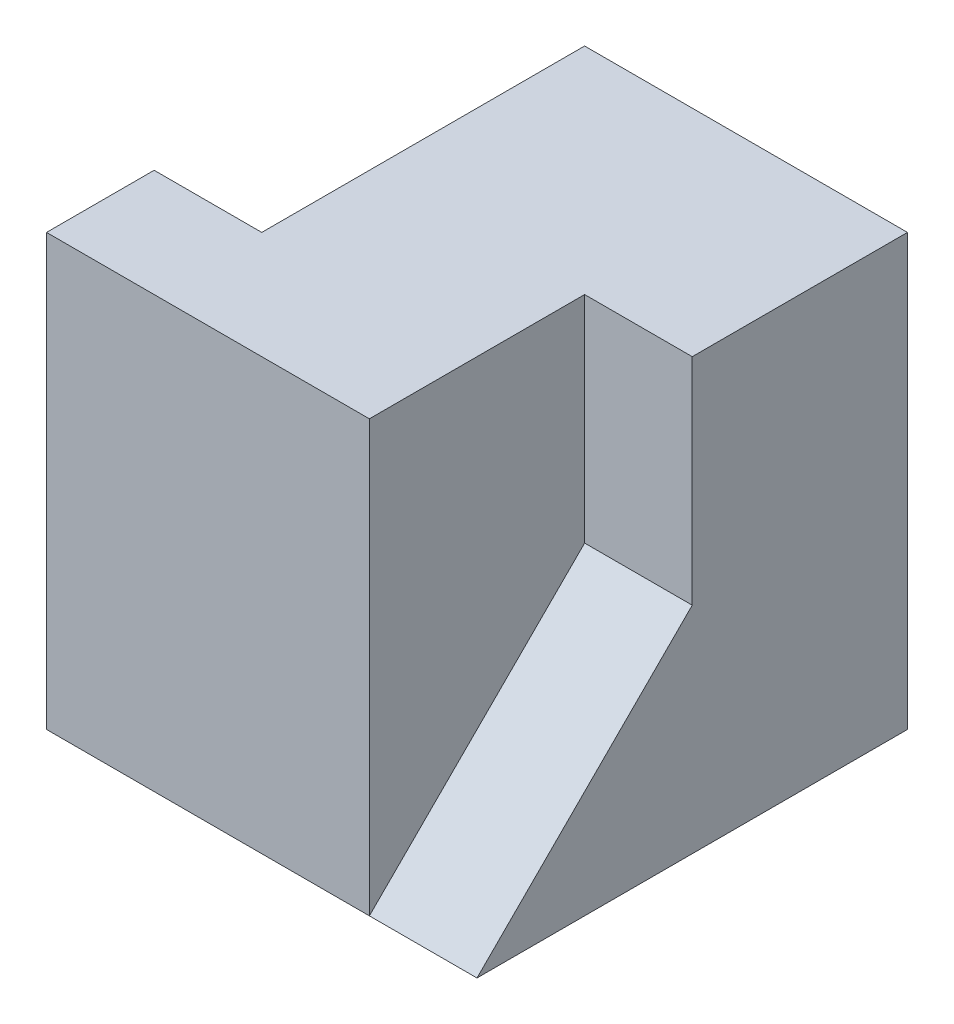
from build123d import *

# Parameters (mm, degrees)
SKETCH1_W           = 40
SKETCH1_H           = 40
BOSS_EXTRUDE1_DEPTH = 40
SKETCH2_W           = 10
SKETCH2_H           = 10
CUT_EXTRUDE1_DEPTH  = 40
SKETCH6_W           = 10
SKETCH6_H           = 20
CUT_EXTRUDE4_DEPTH  = 20
SKETCH7_W           = 10
SKETCH7_H           = 20
CUT_EXTRUDE5_DEPTH  = 10
SKETCH12_W          = 10
SKETCH12_H          = 20
CUT_EXTRUDE11_DEPTH = 10
SKETCH13_W          = 10
SKETCH13_H          = 20
BOSS_EXTRUDE4_DEPTH = 10
CUT_EXTRUDE12_DEPTH = 10
BOSS_EXTRUDE5_DEPTH = 10
CUT_EXTRUDE15_DEPTH = 10


with BuildPart() as part:
    # Sketch1 → Boss-Extrude1 (new body)
    with BuildSketch(Plane.XY):
        with Locations((20, 20)):
            Rectangle(SKETCH1_W, SKETCH1_H)
    extrude(amount=BOSS_EXTRUDE1_DEPTH)

    # Sketch2 → Cut-Extrude1 (cut)
    with BuildSketch(Plane(origin=(0, 40, 0), x_dir=(1, 0, 0), z_dir=(0, 1, 0))):
        with Locations((5, -5)):
            Rectangle(SKETCH2_W, SKETCH2_H)
    extrude(amount=-CUT_EXTRUDE1_DEPTH, mode=Mode.SUBTRACT)

    # Sketch6 → Cut-Extrude4 (cut)
    with BuildSketch(Plane.XY.offset(40)):
        with Locations((35, 30)):
            Rectangle(SKETCH6_W, SKETCH6_H)
    extrude(amount=-CUT_EXTRUDE4_DEPTH, mode=Mode.SUBTRACT)

    # Sketch7 → Cut-Extrude5 (cut)
    with BuildSketch(Plane.XY.offset(40)):
        with Locations((35, 10)):
            Rectangle(SKETCH7_W, SKETCH7_H)
    extrude(amount=-CUT_EXTRUDE5_DEPTH, mode=Mode.SUBTRACT)

    # Sketch12 → Cut-Extrude11 (cut)
    with BuildSketch(Plane(origin=(0, 40, 0), x_dir=(1, 0, 0), z_dir=(0, 1, 0))):
        with Locations((5, -20)):
            Rectangle(SKETCH12_W, SKETCH12_H)
    extrude(amount=-CUT_EXTRUDE11_DEPTH, mode=Mode.SUBTRACT)

    # Sketch13 → Boss-Extrude4 (add)
    with BuildSketch(Plane.XY.offset(30)):
        with Locations((35, 10)):
            Rectangle(SKETCH13_W, SKETCH13_H)
    extrude(amount=BOSS_EXTRUDE4_DEPTH)

    # Sketch15 → Cut-Extrude12 (cut)
    with BuildSketch(Plane(origin=(40, 0, 0), x_dir=(0, 0, -1), z_dir=(1, 0, 0))):
        Polygon((-20, 20), (-40, 0), (-40, 20), align=None)
    extrude(amount=-CUT_EXTRUDE12_DEPTH, mode=Mode.SUBTRACT)

    # Sketch16 → Boss-Extrude5 (add)
    with BuildSketch(Plane.ZY):
        Polygon((30, 40), (25, 30), (30, 30), align=None)
    extrude(amount=-BOSS_EXTRUDE5_DEPTH)

    # Sketch17 → Cut-Extrude15 (cut)
    with BuildSketch(Plane.ZY):
        Polygon((25, 30), (10, 0), (10, 30), align=None)
    extrude(amount=-CUT_EXTRUDE15_DEPTH, mode=Mode.SUBTRACT)


solid = part.part
